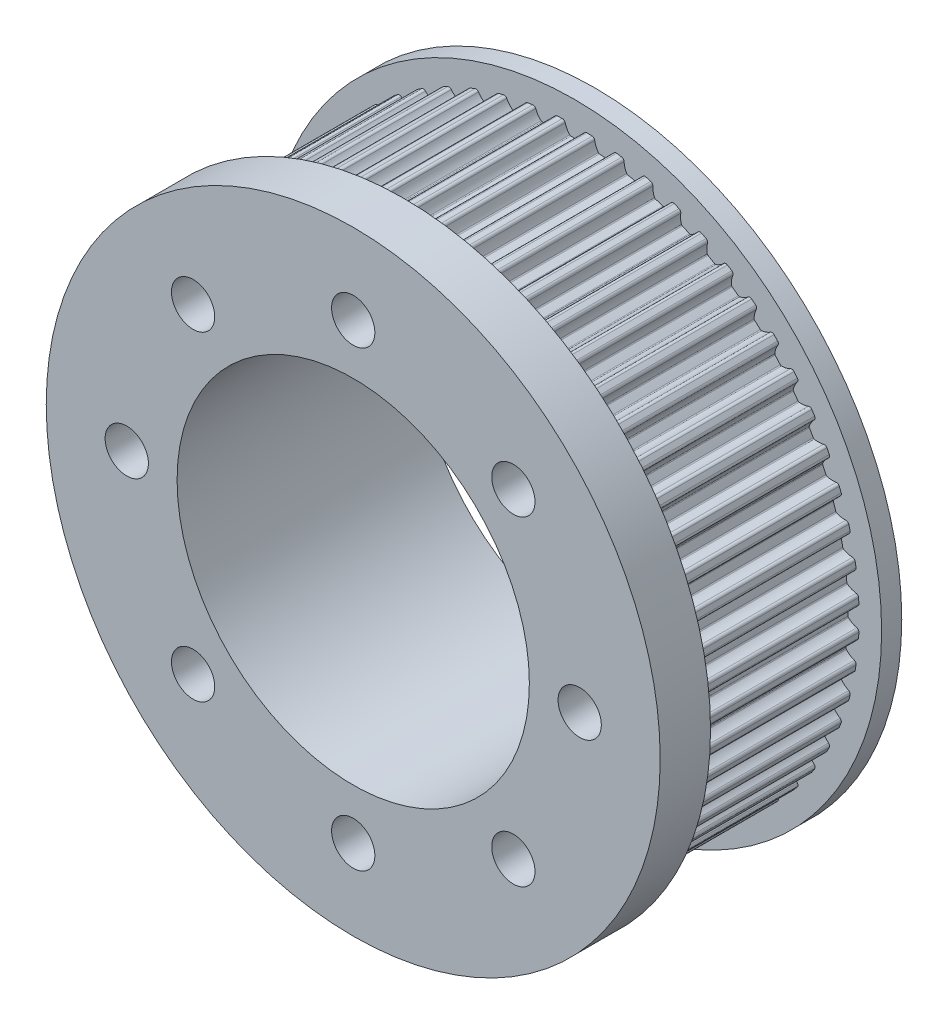
from build123d import *

# Parameters (mm, degrees)
SKETCH_1_R               = 28.265
EXTRUDE_1_DEPTH          = 8.5
CUT_EXTRUDE_START        = -18
CUT_EXTRUDE_1_DEPTH      = 19
PATTERN_CIRCULAR_1_COUNT = 60
SKETCH_3_R               = 30.5
EXTRUDE_2_DEPTH          = 5
SKETCH_9_R               = 30.5
EXTRUDE_3_DEPTH          = 2
SKETCH_4_R               = 17.5
CUT_EXTRUDE_2_DEPTH      = 25
HOLE_WIZARD_M4_2_D       = 4.3
PATTERN_CIRCULAR_2_COUNT = 8


with BuildPart() as part:
    # 草圖1 → 填料-伸長1 (new body, symmetric)
    with BuildSketch(Plane.XY):
        Circle(SKETCH_1_R)
    extrude(amount=EXTRUDE_1_DEPTH, both=True)

    # 草圖2 → 除料-伸長1 (cut)
    with BuildSketch(Plane.XY.offset(8.5).offset(CUT_EXTRUDE_START)):
        with BuildLine():
            ThreePointArc((-0.383112861, 27.152297316), (0, 27.155), (0.383112861, 27.152297316))
            ThreePointArc((0.383112861, 27.152297316), (0.445496306, 27.164922036), (0.49702877, 27.202278199))
            ThreePointArc((0.49702877, 27.202278199), (0.76723869, 27.588822948), (0.938098742, 28.028410353))
            ThreePointArc((0.938098742, 28.028410353), (1.042496742, 28.183734022), (1.221422579, 28.238596847))
            ThreePointArc((1.221422579, 28.238596847), (0, 28.265), (-1.221422579, 28.238596847))
            ThreePointArc((-1.221422579, 28.238596847), (-1.042496742, 28.183734022), (-0.938098742, 28.028410353))
            ThreePointArc((-0.938098742, 28.028410353), (-0.76723869, 27.588822948), (-0.49702877, 27.202278199))
            ThreePointArc((-0.49702877, 27.202278199), (-0.445496306, 27.164922036), (-0.383112861, 27.152297316))
        make_face()
    cut_extrude_1 = extrude(amount=CUT_EXTRUDE_1_DEPTH, mode=Mode.SUBTRACT)

    # 環狀複製排列1: 除料-伸長1 ×60 about axis
    pattern_circular_1_axis = Axis((0, 0, 0), (0, 0, 1))
    for i in range(1, PATTERN_CIRCULAR_1_COUNT):
        add(cut_extrude_1.rotate(pattern_circular_1_axis, i * 360 / PATTERN_CIRCULAR_1_COUNT), mode=Mode.SUBTRACT)

    # 草圖3 → 填料-伸長2 (add)
    with BuildSketch(Plane.XY.offset(8.5)):
        Circle(SKETCH_3_R)
    extrude(amount=EXTRUDE_2_DEPTH)

    # 草圖9 → 填料-伸長3 (add)
    with BuildSketch(Plane(origin=(0, 0, -8.5), x_dir=(-1, 0, 0), z_dir=(0, 0, -1))):
        Circle(SKETCH_9_R)
    extrude(amount=EXTRUDE_3_DEPTH)

    # 草圖4 → 除料-伸長2 (cut, through all)
    with BuildSketch(Plane.XY.offset(13.5)):
        Circle(SKETCH_4_R)
    extrude(amount=-CUT_EXTRUDE_2_DEPTH, mode=Mode.SUBTRACT)

    # M4 餘隙孔2 (through all)
    with Locations(Plane.XY.offset(13.5)):
        with Locations((0, 22.5)):
            hole_wizard_m4_2 = Hole(HOLE_WIZARD_M4_2_D / 2)

    # 環狀複製排列2: M4 餘隙孔2 ×8 about axis
    pattern_circular_2_axis = Axis((0, 0, 0), (0, 0, 1))
    for i in range(1, PATTERN_CIRCULAR_2_COUNT):
        add(hole_wizard_m4_2.rotate(pattern_circular_2_axis, i * 360 / PATTERN_CIRCULAR_2_COUNT), mode=Mode.SUBTRACT)


solid = part.part
